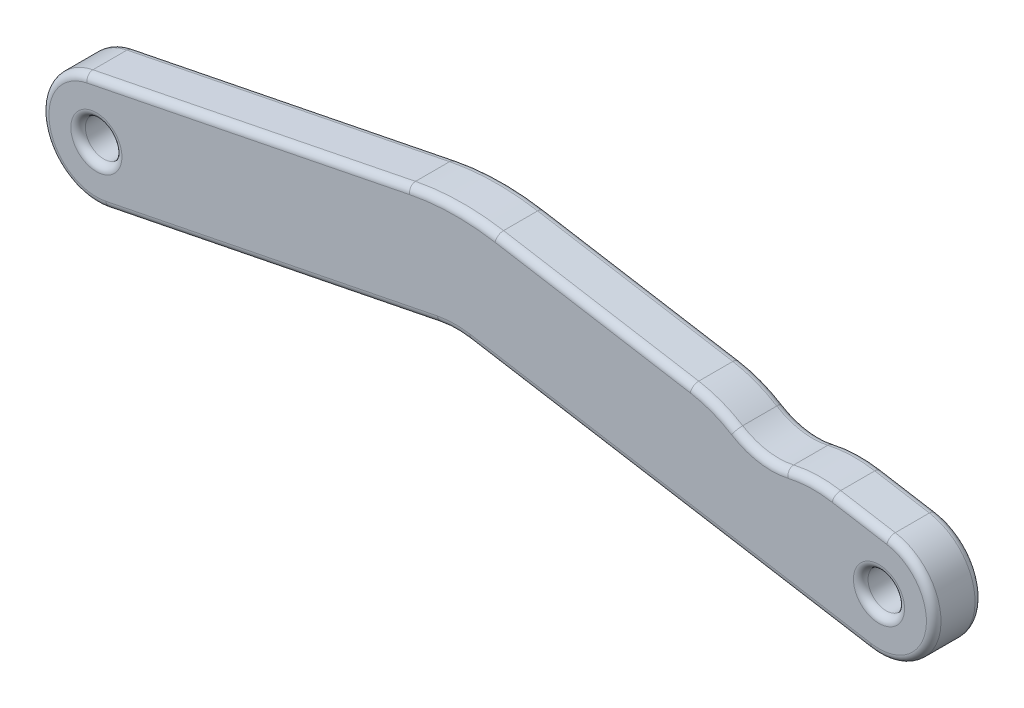
from build123d import *

# Parameters (mm, degrees)
SKETCH1_R               = 0.75
BOSS_EXTRUDE1_DEPTH     = 2
SKETCH3_OUTSIDE_W       = 46.076
SKETCH3_OUTSIDE_H       = 13.9
CUT_EXTRUDE4_DEPTH      = 3
SKETCH4_R               = 0.75
BOSS_EXTRUDE2_DEPTH     = 2
CUT_EXTRUDE6_DEPTH      = 3
CUT_EXTRUDE6_DEPTH_BACK = 1
FILLET1_R               = 0.3


with BuildPart() as part:
    # Sketch1 → Boss-Extrude1 (new body)
    with BuildSketch(Plane.XY):
        with BuildLine():
            Line((0, 2.25), (32.175858, 2.25))
            ThreePointArc((32.175858, 2.25), (34.425858, 0), (32.175858, -2.25))
            Line((32.175858, -2.25), (0, -2.25))
            ThreePointArc((0, -2.25), (-2.25, 0), (0, 2.25))
        make_face()
        Circle(SKETCH1_R, mode=Mode.SUBTRACT)
        with Locations((32.175858, 0)):
            Circle(SKETCH1_R, mode=Mode.SUBTRACT)
    extrude(amount=BOSS_EXTRUDE1_DEPTH)

    # Sketch3 outside → Cut-Extrude4 (cut, through all)
    with BuildSketch(Plane.XY):
        with Locations((16.088, 0)):
            Rectangle(SKETCH3_OUTSIDE_W, SKETCH3_OUTSIDE_H)
        with BuildLine():
            Line((0.442179, -2.206123), (14.078941, 0.527129))
            ThreePointArc((14.078941, 0.527129), (14.6998, 0.593685), (15.322449, 0.546746))
            Line((15.322449, 0.546746), (31.803487, -2.218973))
            ThreePointArc((31.803487, -2.218973), (34.39483, -0.372371), (32.548228, 2.218973))
            Line((32.548228, 2.218973), (16.442082, 4.92178))
            ThreePointArc((16.442082, 4.92178), (14.629366, 5.058435), (12.821862, 4.864669))
            Line((12.821862, 4.864669), (-0.442179, 2.206123))
            ThreePointArc((-0.442179, 2.206123), (-2.206123, -0.442179), (0.442179, -2.206123))
        make_face(mode=Mode.SUBTRACT)
    extrude(amount=CUT_EXTRUDE4_DEPTH, mode=Mode.SUBTRACT)

    # Sketch4 → Boss-Extrude2 (add)
    with BuildSketch(Plane.XY.offset(2)):
        with BuildLine():
            Line((12.821862, 4.864669), (-0.442179, 2.206123))
            ThreePointArc((-0.442179, 2.206123), (-2.206123, -0.442179), (0.442179, -2.206123))
            Line((0.442179, -2.206123), (14.078941, 0.527129))
            ThreePointArc((14.078941, 0.527129), (14.6998, 0.593685), (15.322449, 0.546746))
            Line((15.322449, 0.546746), (31.803487, -2.218973))
            ThreePointArc((31.803487, -2.218973), (34.39483, -0.372371), (32.548228, 2.218973))
            Line((32.548228, 2.218973), (16.442082, 4.92178))
            ThreePointArc((16.442082, 4.92178), (14.629366, 5.058435), (12.821862, 4.864669))
        make_face()
        with Locations((32.175858, 0)):
            Circle(SKETCH4_R, mode=Mode.SUBTRACT)
        Circle(SKETCH4_R, mode=Mode.SUBTRACT)
    extrude(amount=-BOSS_EXTRUDE2_DEPTH)

    # Sketch6 → Cut-Extrude6 (cut, two sides)
    with BuildSketch(Plane.XY) as cut_extrude6_sk:
        with BuildLine():
            Line((24.467465, 3.575023), (23.959016, 3.660347))
            Line((23.959016, 3.660347), (27.36329, 6.266269))
            Line((27.36329, 6.266269), (30.303068, 2.595738))
            ThreePointArc((30.303068, 2.595738), (29.334291, 2.662691), (28.370844, 2.541117))
            ThreePointArc((28.370844, 2.541117), (27.288799, 2.510529), (26.276013, 2.892655))
            ThreePointArc((26.276013, 2.892655), (25.405028, 3.322069), (24.467465, 3.575023))
        make_face()
    extrude(amount=CUT_EXTRUDE6_DEPTH, mode=Mode.SUBTRACT)
    extrude(cut_extrude6_sk.sketch, amount=-CUT_EXTRUDE6_DEPTH_BACK, mode=Mode.SUBTRACT)

    # Fillet1
    fillet1_edges = [part.edges().sort_by_distance(p)[0] for p in [
        (31.425858, 0, 0),
        (-0.75, 0, 0),
        (7.26056, -0.839497, 0),
        (14.6998, 0.593685, 0),
        (23.562968, -0.836113, 0),
        (14.629366, 5.058435, 2),
        (14.629366, 5.058435, 0),
        (6.189842, 3.535396, 2),
        (6.189842, 3.535396, 0),
        (-2.239004, -0.222175, 0),
        (31.425858, 0, 2),
        (-0.75, 0, 2),
        (23.562968, -0.836113, 2),
        (14.6998, 0.593685, 2),
        (7.26056, -0.839497, 2),
        (-2.239004, -0.222175, 2),
        (20.200549, 4.291063, 2),
        (20.200549, 4.291063, 0),
        (34.418087, -0.186831, 0),
        (31.425648, 2.407355, 2),
        (31.425648, 2.407355, 0),
        (34.418087, -0.186831, 2),
        (25.405028, 3.322069, 0),
        (29.334291, 2.662691, 0),
        (27.288799, 2.510529, 0),
        (25.405028, 3.322069, 2),
        (27.288799, 2.510529, 2),
        (29.334291, 2.662691, 2),
    ]]
    fillet(fillet1_edges, radius=FILLET1_R)


solid = part.part
